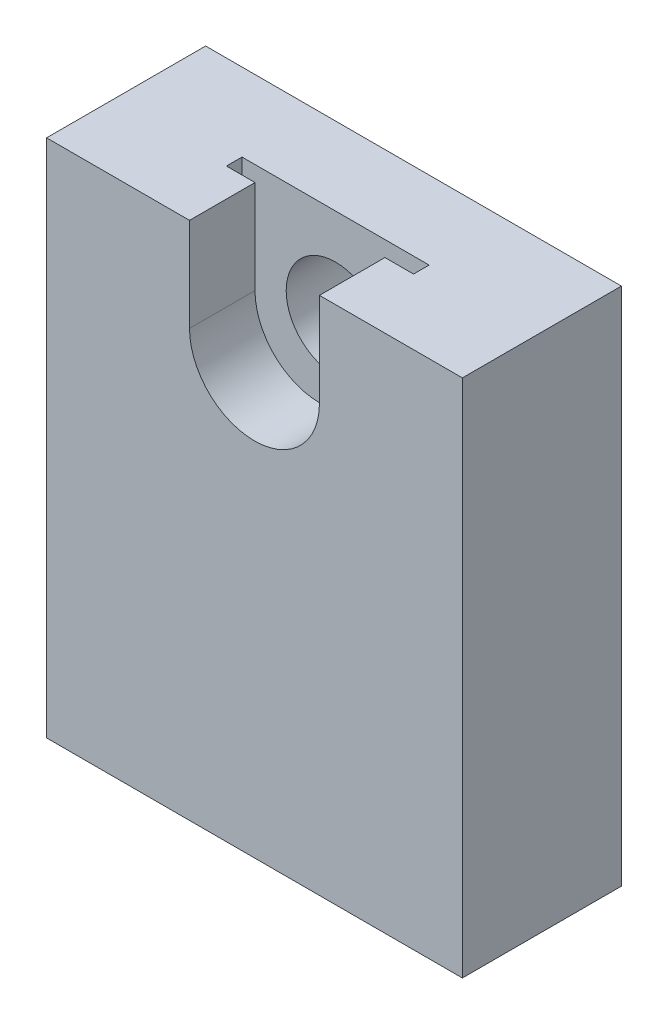
from build123d import *

# Parameters (mm, degrees)
BOSS_EXTRUDE1_DEPTH = 15.3
SKETCH3_R           = 4.75
BOSS_EXTRUDE2_DEPTH = 9
CUT_EXTRUDE1_DEPTH  = 1.5


with BuildPart() as part:
    # Sketch2 → Boss-Extrude1 (new body)
    with BuildSketch(Plane.XY):
        with BuildLine():
            Line((-20, 9), (-20, -41))
            Line((-20, -41), (20, -41))
            Line((20, -41), (20, 9))
            Line((20, 9), (6.25, 9))
            Line((6.25, 9), (6.25, 0))
            ThreePointArc((6.25, 0), (0, -6.25), (-6.25, 0))
            Line((-6.25, 0), (-6.25, 9))
            Line((-6.25, 9), (-20, 9))
        make_face()
    extrude(amount=-BOSS_EXTRUDE1_DEPTH)

    # Sketch3 → Boss-Extrude2 (add)
    with BuildSketch(Plane(origin=(0, 0, -15.3), x_dir=(-1, 0, 0), z_dir=(0, 0, -1))):
        with BuildLine():
            Line((6.25, 0), (6.25, 9))
            Line((6.25, 9), (-6.25, 9))
            Line((-6.25, 9), (-6.25, 0))
            ThreePointArc((-6.25, 0), (0, -6.25), (6.25, 0))
        make_face()
        Circle(SKETCH3_R, mode=Mode.SUBTRACT)
    extrude(amount=-BOSS_EXTRUDE2_DEPTH)

    # Sketch4 → Cut-Extrude1 (cut)
    with BuildSketch(Plane.XY.offset(-6.3)):
        with BuildLine():
            Line((-9, 0), (-9, 9))
            ThreePointArc((-9, 9), (0, 18), (9, 9))
            Line((9, 9), (9, 0))
            ThreePointArc((9, 0), (0, -9), (-9, 0))
        make_face()
    extrude(amount=-CUT_EXTRUDE1_DEPTH, mode=Mode.SUBTRACT)


solid = part.part
